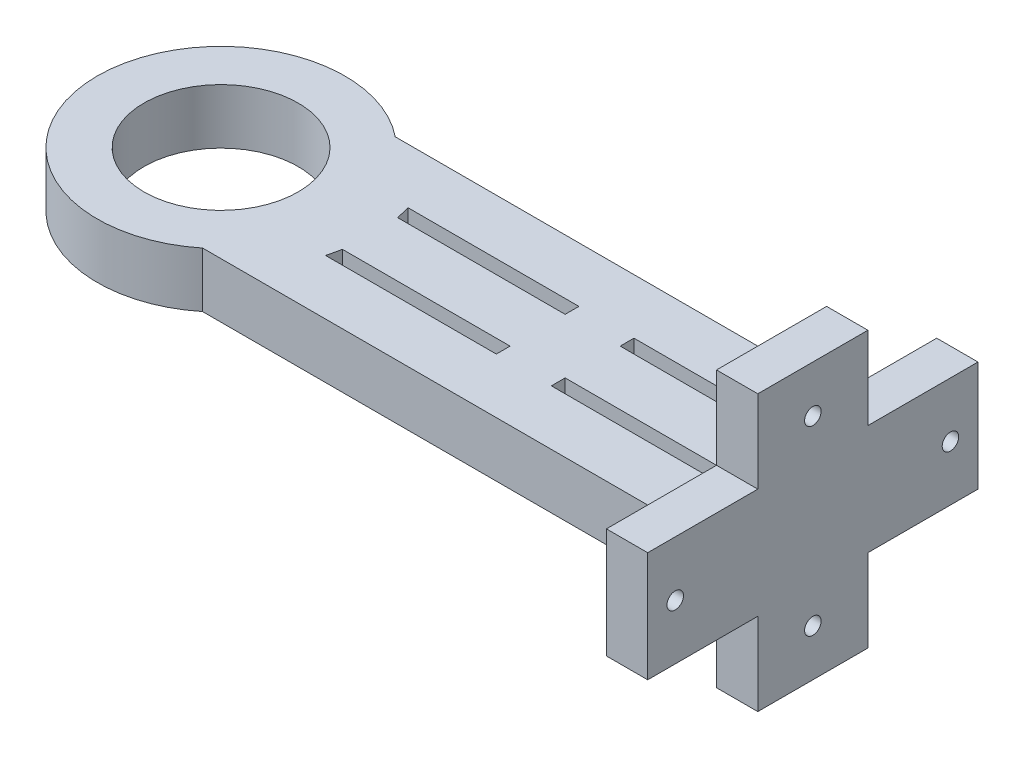
from build123d import *

# Parameters (mm, degrees)
BOSS_EXTRUDE1_DEPTH = 20
SKETCH3_R           = 28
CUT_EXTRUDE2_DEPTH  = 21
SKETCH5_W           = 15
SKETCH5_H           = 120
BOSS_EXTRUDE3_DEPTH = 10
SKETCH6_W           = 15
SKETCH6_H           = 40
BOSS_EXTRUDE4_DEPTH = 30
SKETCH10_R          = 7.5
CUT_EXTRUDE8_DEPTH  = 2
SKETCH11_R          = 3
CUT_EXTRUDE9_DEPTH  = 14
SKETCH12_R          = 7.5
CUT_EXTRUDE10_DEPTH = 2
SKETCH13_R          = 3
CUT_EXTRUDE11_DEPTH = 14
SKETCH14_W          = 20
SKETCH14_H          = 5
BOSS_EXTRUDE5_DEPTH = 20


with BuildPart() as part:
    # Sketch1 → Boss-Extrude1 (new body)
    with BuildSketch(Plane(origin=(0, 0, 0), x_dir=(1, 0, 0), z_dir=(0, 1, 0))):
        with BuildLine():
            Line((-45, 0), (215, 0))
            Line((215, 0), (215, 60))
            Line((215, 60), (200, 60))
            Line((200, 60), (200, 35))
            Line((200, 35), (28.284271247, 35))
            ThreePointArc((28.284271247, 35), (-19.393398282, 40.606601718), (-45, 0))
        make_face()
        with BuildLine():
            Line((200, 15), (200, 10))
            Line((200, 10), (54.083269132, 10))
            ThreePointArc((54.083269132, 10), (53.557527969, 12.513640472), (52.915026221, 15))
            Line((52.915026221, 15), (200, 15))
        make_face(mode=Mode.SUBTRACT)
    boss_extrude1 = extrude(amount=BOSS_EXTRUDE1_DEPTH)

    # Mirror2: Boss-Extrude1 across plane
    add(boss_extrude1.mirror(Plane(origin=(-45, 20, 0), x_dir=(1, 0, 0), z_dir=(0, 0, -1))))

    # Sketch3 → Cut-Extrude2 (cut, through all)
    with BuildSketch(Plane(origin=(0, 20, 0), x_dir=(1, 0, 0), z_dir=(0, 1, 0))):
        Circle(SKETCH3_R)
    extrude(amount=-CUT_EXTRUDE2_DEPTH, mode=Mode.SUBTRACT)

    # Sketch5 → Boss-Extrude3 (add)
    with BuildSketch(Plane.XZ):
        with Locations((207.5, 0)):
            Rectangle(SKETCH5_W, SKETCH5_H)
    boss_extrude3 = extrude(amount=BOSS_EXTRUDE3_DEPTH)

    # Sketch6 → Boss-Extrude4 (add)
    with BuildSketch(Plane.XZ.offset(10)):
        with Locations((207.5, 0)):
            Rectangle(SKETCH6_W, SKETCH6_H)
    boss_extrude4 = extrude(amount=BOSS_EXTRUDE4_DEPTH)

    # Mirror5: Boss-Extrude3 across plane
    add(boss_extrude3.mirror(Plane(origin=(0, 10, 0), x_dir=(0, 0, 1), z_dir=(0, -1, 0))))

    # Mirror6: Boss-Extrude4 across plane
    add(boss_extrude4.mirror(Plane(origin=(0, 10, 0), x_dir=(0, 0, 1), z_dir=(0, -1, 0))))

    # Sketch10 → Cut-Extrude8 (cut)
    with BuildSketch(Plane.ZY.offset(-200)):
        with Locations((0, -23)):
            Circle(SKETCH10_R)
    cut_extrude8 = extrude(amount=-CUT_EXTRUDE8_DEPTH, mode=Mode.SUBTRACT)

    # Sketch11 → Cut-Extrude9 (cut, through all)
    with BuildSketch(Plane.ZY.offset(-202)):
        with Locations((0, -23)):
            Circle(SKETCH11_R)
    cut_extrude9 = extrude(amount=-CUT_EXTRUDE9_DEPTH, mode=Mode.SUBTRACT)

    # Sketch12 → Cut-Extrude10 (cut)
    with BuildSketch(Plane.ZY.offset(-200)):
        with Locations((-50, 10)):
            Circle(SKETCH12_R)
    cut_extrude10 = extrude(amount=-CUT_EXTRUDE10_DEPTH, mode=Mode.SUBTRACT)

    # Sketch13 → Cut-Extrude11 (cut, through all)
    with BuildSketch(Plane.ZY.offset(-202)):
        with Locations((-50, 10)):
            Circle(SKETCH13_R)
    cut_extrude11 = extrude(amount=-CUT_EXTRUDE11_DEPTH, mode=Mode.SUBTRACT)

    # Mirror7: Cut-Extrude10, Cut-Extrude11 across plane
    add(cut_extrude10.mirror(Plane.XY), mode=Mode.SUBTRACT)
    add(cut_extrude11.mirror(Plane.XY), mode=Mode.SUBTRACT)

    # Mirror8: Cut-Extrude8, Cut-Extrude9 across plane
    add(cut_extrude8.mirror(Plane(origin=(0, 10, 0), x_dir=(0, 0, 1), z_dir=(0, -1, 0))), mode=Mode.SUBTRACT)
    add(cut_extrude9.mirror(Plane(origin=(0, 10, 0), x_dir=(0, 0, 1), z_dir=(0, -1, 0))), mode=Mode.SUBTRACT)

    # Sketch14 → Boss-Extrude5 (add)
    with BuildSketch(Plane(origin=(0, 20, 0), x_dir=(1, 0, 0), z_dir=(0, 1, 0))):
        with Locations((125, 12.5)):
            Rectangle(SKETCH14_W, SKETCH14_H)
    boss_extrude5 = extrude(amount=-BOSS_EXTRUDE5_DEPTH)

    # Mirror9: Boss-Extrude5 across plane
    add(boss_extrude5.mirror(Plane.XY))


with BuildPart() as body_2:
    # Split1: the piece on the far side of the plane
    add(part.part)
    split(bisect_by=Plane(origin=(200, 0, 0), x_dir=(0, 0, -1), z_dir=(-1, 0, 0)), keep=Keep.BOTTOM)


with BuildPart() as part_1:
    add(part.part)

    # Split1
    split(bisect_by=Plane(origin=(200, 0, 0), x_dir=(0, 0, -1), z_dir=(-1, 0, 0)), keep=Keep.TOP)


solid = Compound([body_2.part, part_1.part])
